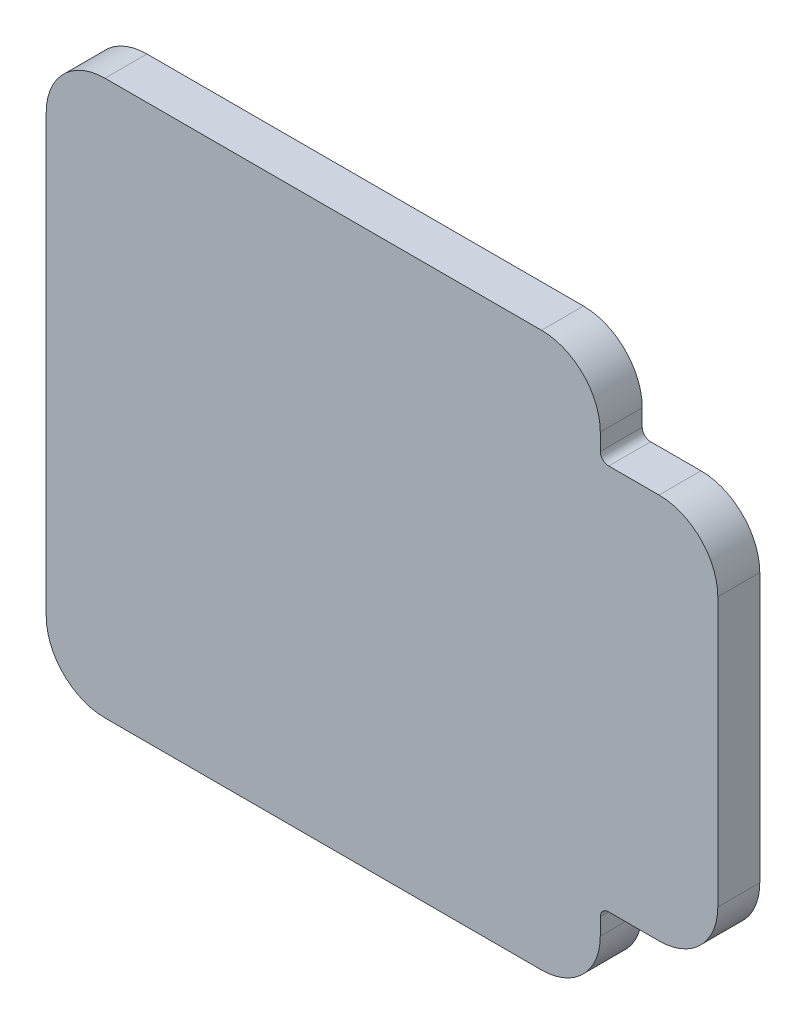
from build123d import *

# Parameters (mm, degrees)
BOSS_EXTRUDE2_DEPTH = 2.5


with BuildPart() as part:
    # Glass_Sketch → Boss-Extrude2 (new body)
    with BuildSketch(Plane.XY):
        with BuildLine():
            Line((-10.296075652, -23.145089286), (-10.296075652, 2.854910714))
            ThreePointArc((-10.296075652, 2.854910714), (-9.270949386, 5.329784448), (-6.796075652, 6.354910714))
            Line((-6.796075652, 6.354910714), (19.203924348, 6.354910714))
            ThreePointArc((19.203924348, 6.354910714), (21.678798083, 5.329784448), (22.703924348, 2.854910714))
            Line((22.703924348, 2.854910714), (22.703924348, 1.854910714))
            ThreePointArc((22.703924348, 1.854910714), (22.850370958, 1.501357324), (23.203924348, 1.354910714))
            Line((23.203924348, 1.354910714), (26.203924348, 1.354910714))
            ThreePointArc((26.203924348, 1.354910714), (28.678798083, 0.329784448), (29.703924348, -2.145089286))
            Line((29.703924348, -2.145089286), (29.703924348, -18.145089286))
            ThreePointArc((29.703924348, -18.145089286), (28.678798083, -20.61996302), (26.203924348, -21.645089286))
            Line((26.203924348, -21.645089286), (23.203924348, -21.645089286))
            ThreePointArc((23.203924348, -21.645089286), (22.850370958, -21.791535895), (22.703924348, -22.145089286))
            Line((22.703924348, -22.145089286), (22.703924348, -23.145089286))
            ThreePointArc((22.703924348, -23.145089286), (21.678798083, -25.61996302), (19.203924348, -26.645089286))
            Line((19.203924348, -26.645089286), (-6.796075652, -26.645089286))
            ThreePointArc((-6.796075652, -26.645089286), (-9.270949386, -25.61996302), (-10.296075652, -23.145089286))
        make_face()
    extrude(amount=BOSS_EXTRUDE2_DEPTH)


solid = part.part
